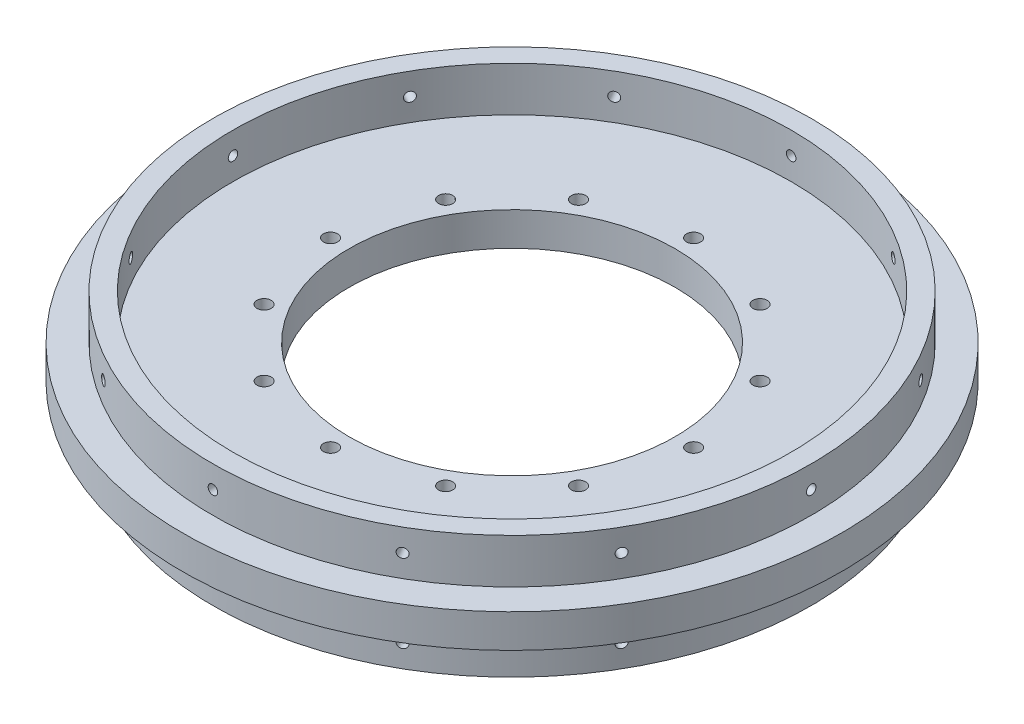
from build123d import *

# Parameters (mm, degrees)
SKETCH1_W           = 127.635
SKETCH1_H           = 127.635
BOSS_EXTRUDE1_DEPTH = 9.525
SKETCH12_R          = 93.726
BOSS_EXTRUDE2_DEPTH = 9.525
SKETCH5_R           = 46.355
CUT_EXTRUDE1_DEPTH  = 9.525
SKETCH11_R          = 2.0193
CUT_EXTRUDE3_DEPTH  = 10.525
CIRPATTERN1_COUNT   = 12
SKETCH30_R          = 85.09
SKETCH30_R_2        = 79.375
BOSS_EXTRUDE3_DEPTH = 12.7
SKETCH32_R          = 1.35255
CUT_EXTRUDE4_DEPTH  = 15.24
CIRPATTERN2_COUNT   = 12


with BuildPart() as part:
    # Sketch1 → Boss-Extrude1 (new body)
    with BuildSketch(Plane(origin=(0, 0, 0), x_dir=(1, 0, 0), z_dir=(0, 1, 0))):
        with Locations((63.8175, 63.8175)):
            Rectangle(SKETCH1_W, SKETCH1_H)
    extrude(amount=BOSS_EXTRUDE1_DEPTH)

    # Sketch12 → Boss-Extrude2 (add)
    with BuildSketch(Plane.XZ):
        with Locations((63.8175, -63.8175)):
            Circle(SKETCH12_R)
    extrude(amount=-BOSS_EXTRUDE2_DEPTH)

    # Sketch5 → Cut-Extrude1 (cut)
    with BuildSketch(Plane(origin=(0, 9.525, 0), x_dir=(1, 0, 0), z_dir=(0, 1, 0))):
        with Locations((63.8175, 63.8175)):
            Circle(SKETCH5_R)
    extrude(amount=-CUT_EXTRUDE1_DEPTH, mode=Mode.SUBTRACT)

    # Sketch11 → Cut-Extrude3 (cut, through all)
    with BuildSketch(Plane(origin=(0, 9.525, 0), x_dir=(1, 0, 0), z_dir=(0, 1, 0))):
        with Locations((63.8175, 115.443)):
            Circle(SKETCH11_R)
    cut_extrude3 = extrude(amount=-CUT_EXTRUDE3_DEPTH, mode=Mode.SUBTRACT)

    # CirPattern1: Cut-Extrude3 ×12 about axis
    cirpattern1_axis = Axis((63.8175, 0, -63.8175), (0, 1, 0))
    for i in range(1, CIRPATTERN1_COUNT):
        add(cut_extrude3.rotate(cirpattern1_axis, i * 360 / CIRPATTERN1_COUNT), mode=Mode.SUBTRACT)

    # Sketch30 → Boss-Extrude3 (add)
    with BuildSketch(Plane.XZ):
        with Locations((63.8175, -63.8175)):
            Circle(SKETCH30_R)
        with Locations((63.8175, -63.8175)):
            Circle(SKETCH30_R_2, mode=Mode.SUBTRACT)
    boss_extrude3 = extrude(amount=BOSS_EXTRUDE3_DEPTH)

    # Mirror1: Boss-Extrude3 across plane
    add(boss_extrude3.mirror(Plane.ZX.offset(4.7625)))

    # Sketch32 → Cut-Extrude4 (cut)
    with BuildSketch(Plane(origin=(0, 0, -148.9075), x_dir=(-1, 0, 0), z_dir=(0, 0, -1))):
        with Locations((-63.8175, -6.35)):
            Circle(SKETCH32_R)
        with Locations((-63.8175, 15.875)):
            Circle(SKETCH32_R)
    cut_extrude4 = extrude(amount=-CUT_EXTRUDE4_DEPTH, mode=Mode.SUBTRACT)

    # CirPattern2: Cut-Extrude4 ×12 about axis
    cirpattern2_axis = Axis((63.8175, -12.7, -63.8175), (0, 1, 0))
    for i in range(1, CIRPATTERN2_COUNT):
        add(cut_extrude4.rotate(cirpattern2_axis, i * 360 / CIRPATTERN2_COUNT), mode=Mode.SUBTRACT)


solid = part.part
